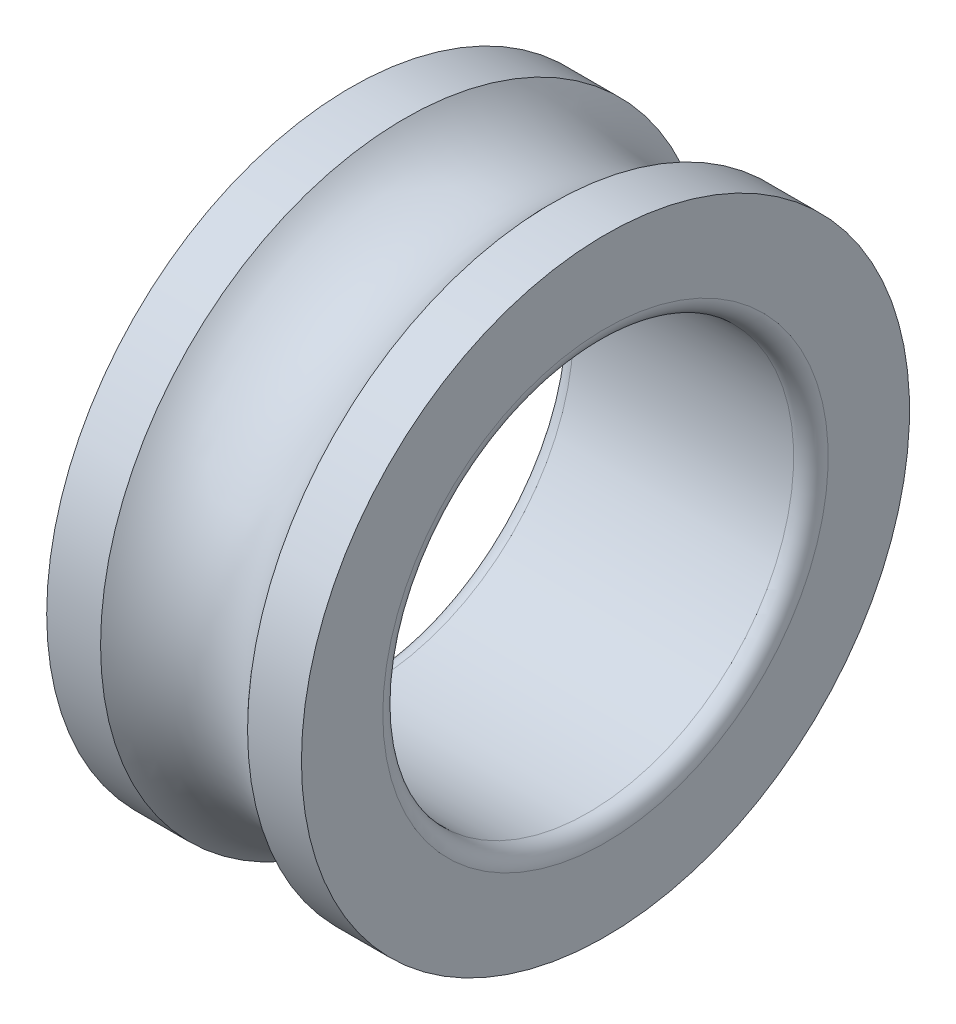
from build123d import *

# Parameters (mm, degrees)
SCALE1_SCALE = 1.2
SCALE2_SCALE = 0.1


with BuildPart() as part:
    # Sketch1 → Revolve1 (revolve)
    with BuildSketch(Plane.XY):
        with BuildLine():
            Line((-13.4, 25), (13.4, 25))
            ThreePointArc((13.4, 25), (14.88492424, 25.61507576), (15.5, 27.1))
            Line((15.5, 27.1), (15.5, 37))
            Line((15.5, 37), (8.94427191, 37))
            ThreePointArc((8.94427191, 37), (0, 33), (-8.94427191, 37))
            Line((-8.94427191, 37), (-15.5, 37))
            Line((-15.5, 37), (-15.5, 27.1))
            ThreePointArc((-15.5, 27.1), (-14.88492424, 25.61507576), (-13.4, 25))
        make_face()
    revolve(axis=Axis((-24.473684211, 0, 0), (1, 0, 0)))


with BuildPart() as part_1:
    # Scale1: scaled about (0, 0, 0)
    add(part.part.scale(SCALE1_SCALE))


with BuildPart() as part_2:
    # Scale2: scaled about (0, 0, 0)
    add(part_1.part.scale(SCALE2_SCALE))


solid = part_2.part
